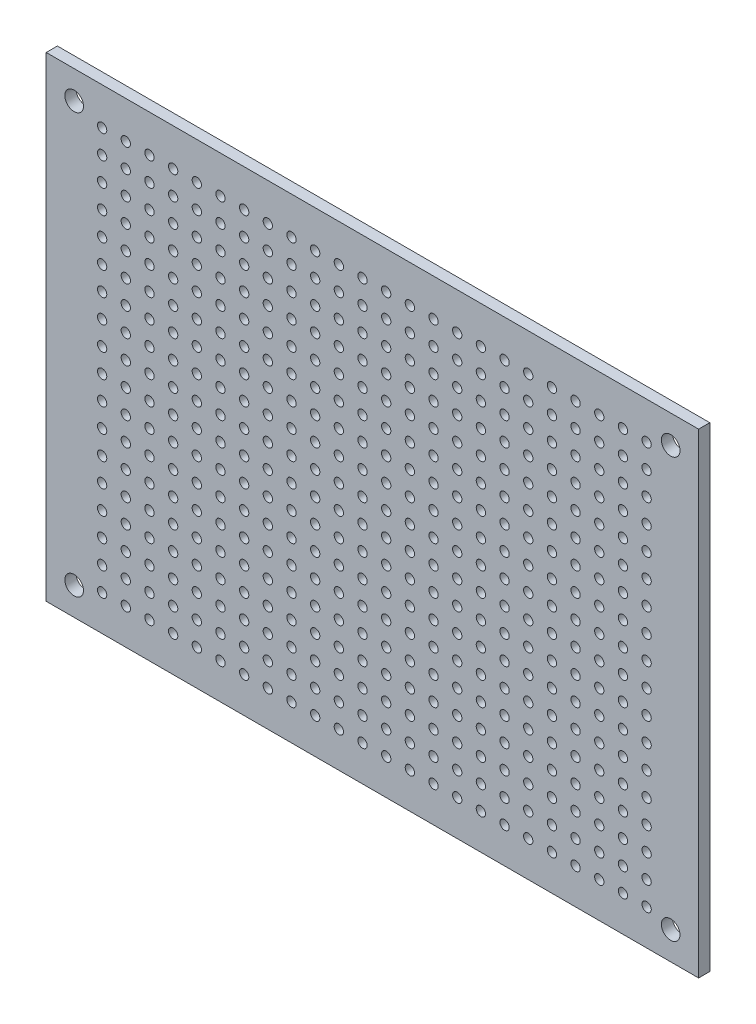
from build123d import *

# Parameters (mm, degrees)
SKETCH_1_W      = 70
SKETCH_1_H      = 51
SKETCH_1_R      = 0.5
SKETCH_1_R_2    = 1
EXTRUDE_1_DEPTH = 1.2


with BuildPart() as part:
    # Эскиз1 → Бобышка-Вытянуть1 (new body)
    with BuildSketch(Plane.XY):
        with Locations((35, 25.5)):
            Rectangle(SKETCH_1_W, SKETCH_1_H)
        with Locations((6, 47)):
            Circle(SKETCH_1_R, mode=Mode.SUBTRACT)
        with Locations((3, 48)):
            Circle(SKETCH_1_R_2, mode=Mode.SUBTRACT)
        with Locations((67, 48)):
            Circle(SKETCH_1_R_2, mode=Mode.SUBTRACT)
        with Locations((67, 3)):
            Circle(SKETCH_1_R_2, mode=Mode.SUBTRACT)
        with Locations((3, 3)):
            Circle(SKETCH_1_R_2, mode=Mode.SUBTRACT)
        with Locations((8.54, 47)):
            Circle(SKETCH_1_R, mode=Mode.SUBTRACT)
        with Locations((11.08, 47)):
            Circle(SKETCH_1_R, mode=Mode.SUBTRACT)
        with Locations((13.62, 47)):
            Circle(SKETCH_1_R, mode=Mode.SUBTRACT)
        with Locations((16.16, 47)):
            Circle(SKETCH_1_R, mode=Mode.SUBTRACT)
        with Locations((18.7, 47)):
            Circle(SKETCH_1_R, mode=Mode.SUBTRACT)
        with Locations((21.24, 47)):
            Circle(SKETCH_1_R, mode=Mode.SUBTRACT)
        with Locations((23.78, 47)):
            Circle(SKETCH_1_R, mode=Mode.SUBTRACT)
        with Locations((26.32, 47)):
            Circle(SKETCH_1_R, mode=Mode.SUBTRACT)
        with Locations((28.86, 47)):
            Circle(SKETCH_1_R, mode=Mode.SUBTRACT)
        with Locations((31.4, 47)):
            Circle(SKETCH_1_R, mode=Mode.SUBTRACT)
        with Locations((33.94, 47)):
            Circle(SKETCH_1_R, mode=Mode.SUBTRACT)
        with Locations((36.48, 47)):
            Circle(SKETCH_1_R, mode=Mode.SUBTRACT)
        with Locations((39.02, 47)):
            Circle(SKETCH_1_R, mode=Mode.SUBTRACT)
        with Locations((41.56, 47)):
            Circle(SKETCH_1_R, mode=Mode.SUBTRACT)
        with Locations((44.1, 47)):
            Circle(SKETCH_1_R, mode=Mode.SUBTRACT)
        with Locations((46.64, 47)):
            Circle(SKETCH_1_R, mode=Mode.SUBTRACT)
        with Locations((49.18, 47)):
            Circle(SKETCH_1_R, mode=Mode.SUBTRACT)
        with Locations((51.72, 47)):
            Circle(SKETCH_1_R, mode=Mode.SUBTRACT)
        with Locations((54.26, 47)):
            Circle(SKETCH_1_R, mode=Mode.SUBTRACT)
        with Locations((56.8, 47)):
            Circle(SKETCH_1_R, mode=Mode.SUBTRACT)
        with Locations((59.34, 47)):
            Circle(SKETCH_1_R, mode=Mode.SUBTRACT)
        with Locations((61.88, 47)):
            Circle(SKETCH_1_R, mode=Mode.SUBTRACT)
        with Locations((64.42, 47)):
            Circle(SKETCH_1_R, mode=Mode.SUBTRACT)
        with Locations((8.54, 44.46)):
            Circle(SKETCH_1_R, mode=Mode.SUBTRACT)
        with Locations((11.08, 44.46)):
            Circle(SKETCH_1_R, mode=Mode.SUBTRACT)
        with Locations((13.62, 44.46)):
            Circle(SKETCH_1_R, mode=Mode.SUBTRACT)
        with Locations((16.16, 44.46)):
            Circle(SKETCH_1_R, mode=Mode.SUBTRACT)
        with Locations((18.7, 44.46)):
            Circle(SKETCH_1_R, mode=Mode.SUBTRACT)
        with Locations((21.24, 44.46)):
            Circle(SKETCH_1_R, mode=Mode.SUBTRACT)
        with Locations((23.78, 44.46)):
            Circle(SKETCH_1_R, mode=Mode.SUBTRACT)
        with Locations((26.32, 44.46)):
            Circle(SKETCH_1_R, mode=Mode.SUBTRACT)
        with Locations((28.86, 44.46)):
            Circle(SKETCH_1_R, mode=Mode.SUBTRACT)
        with Locations((31.4, 44.46)):
            Circle(SKETCH_1_R, mode=Mode.SUBTRACT)
        with Locations((33.94, 44.46)):
            Circle(SKETCH_1_R, mode=Mode.SUBTRACT)
        with Locations((36.48, 44.46)):
            Circle(SKETCH_1_R, mode=Mode.SUBTRACT)
        with Locations((39.02, 44.46)):
            Circle(SKETCH_1_R, mode=Mode.SUBTRACT)
        with Locations((41.56, 44.46)):
            Circle(SKETCH_1_R, mode=Mode.SUBTRACT)
        with Locations((44.1, 44.46)):
            Circle(SKETCH_1_R, mode=Mode.SUBTRACT)
        with Locations((46.64, 44.46)):
            Circle(SKETCH_1_R, mode=Mode.SUBTRACT)
        with Locations((49.18, 44.46)):
            Circle(SKETCH_1_R, mode=Mode.SUBTRACT)
        with Locations((51.72, 44.46)):
            Circle(SKETCH_1_R, mode=Mode.SUBTRACT)
        with Locations((54.26, 44.46)):
            Circle(SKETCH_1_R, mode=Mode.SUBTRACT)
        with Locations((56.8, 44.46)):
            Circle(SKETCH_1_R, mode=Mode.SUBTRACT)
        with Locations((59.34, 44.46)):
            Circle(SKETCH_1_R, mode=Mode.SUBTRACT)
        with Locations((61.88, 44.46)):
            Circle(SKETCH_1_R, mode=Mode.SUBTRACT)
        with Locations((64.42, 44.46)):
            Circle(SKETCH_1_R, mode=Mode.SUBTRACT)
        with Locations((8.54, 41.92)):
            Circle(SKETCH_1_R, mode=Mode.SUBTRACT)
        with Locations((11.08, 41.92)):
            Circle(SKETCH_1_R, mode=Mode.SUBTRACT)
        with Locations((13.62, 41.92)):
            Circle(SKETCH_1_R, mode=Mode.SUBTRACT)
        with Locations((16.16, 41.92)):
            Circle(SKETCH_1_R, mode=Mode.SUBTRACT)
        with Locations((18.7, 41.92)):
            Circle(SKETCH_1_R, mode=Mode.SUBTRACT)
        with Locations((21.24, 41.92)):
            Circle(SKETCH_1_R, mode=Mode.SUBTRACT)
        with Locations((23.78, 41.92)):
            Circle(SKETCH_1_R, mode=Mode.SUBTRACT)
        with Locations((26.32, 41.92)):
            Circle(SKETCH_1_R, mode=Mode.SUBTRACT)
        with Locations((28.86, 41.92)):
            Circle(SKETCH_1_R, mode=Mode.SUBTRACT)
        with Locations((31.4, 41.92)):
            Circle(SKETCH_1_R, mode=Mode.SUBTRACT)
        with Locations((33.94, 41.92)):
            Circle(SKETCH_1_R, mode=Mode.SUBTRACT)
        with Locations((36.48, 41.92)):
            Circle(SKETCH_1_R, mode=Mode.SUBTRACT)
        with Locations((39.02, 41.92)):
            Circle(SKETCH_1_R, mode=Mode.SUBTRACT)
        with Locations((41.56, 41.92)):
            Circle(SKETCH_1_R, mode=Mode.SUBTRACT)
        with Locations((44.1, 41.92)):
            Circle(SKETCH_1_R, mode=Mode.SUBTRACT)
        with Locations((46.64, 41.92)):
            Circle(SKETCH_1_R, mode=Mode.SUBTRACT)
        with Locations((49.18, 41.92)):
            Circle(SKETCH_1_R, mode=Mode.SUBTRACT)
        with Locations((51.72, 41.92)):
            Circle(SKETCH_1_R, mode=Mode.SUBTRACT)
        with Locations((54.26, 41.92)):
            Circle(SKETCH_1_R, mode=Mode.SUBTRACT)
        with Locations((56.8, 41.92)):
            Circle(SKETCH_1_R, mode=Mode.SUBTRACT)
        with Locations((59.34, 41.92)):
            Circle(SKETCH_1_R, mode=Mode.SUBTRACT)
        with Locations((61.88, 41.92)):
            Circle(SKETCH_1_R, mode=Mode.SUBTRACT)
        with Locations((64.42, 41.92)):
            Circle(SKETCH_1_R, mode=Mode.SUBTRACT)
        with Locations((8.54, 39.38)):
            Circle(SKETCH_1_R, mode=Mode.SUBTRACT)
        with Locations((11.08, 39.38)):
            Circle(SKETCH_1_R, mode=Mode.SUBTRACT)
        with Locations((13.62, 39.38)):
            Circle(SKETCH_1_R, mode=Mode.SUBTRACT)
        with Locations((16.16, 39.38)):
            Circle(SKETCH_1_R, mode=Mode.SUBTRACT)
        with Locations((18.7, 39.38)):
            Circle(SKETCH_1_R, mode=Mode.SUBTRACT)
        with Locations((21.24, 39.38)):
            Circle(SKETCH_1_R, mode=Mode.SUBTRACT)
        with Locations((23.78, 39.38)):
            Circle(SKETCH_1_R, mode=Mode.SUBTRACT)
        with Locations((26.32, 39.38)):
            Circle(SKETCH_1_R, mode=Mode.SUBTRACT)
        with Locations((28.86, 39.38)):
            Circle(SKETCH_1_R, mode=Mode.SUBTRACT)
        with Locations((31.4, 39.38)):
            Circle(SKETCH_1_R, mode=Mode.SUBTRACT)
        with Locations((33.94, 39.38)):
            Circle(SKETCH_1_R, mode=Mode.SUBTRACT)
        with Locations((36.48, 39.38)):
            Circle(SKETCH_1_R, mode=Mode.SUBTRACT)
        with Locations((39.02, 39.38)):
            Circle(SKETCH_1_R, mode=Mode.SUBTRACT)
        with Locations((41.56, 39.38)):
            Circle(SKETCH_1_R, mode=Mode.SUBTRACT)
        with Locations((44.1, 39.38)):
            Circle(SKETCH_1_R, mode=Mode.SUBTRACT)
        with Locations((46.64, 39.38)):
            Circle(SKETCH_1_R, mode=Mode.SUBTRACT)
        with Locations((49.18, 39.38)):
            Circle(SKETCH_1_R, mode=Mode.SUBTRACT)
        with Locations((51.72, 39.38)):
            Circle(SKETCH_1_R, mode=Mode.SUBTRACT)
        with Locations((54.26, 39.38)):
            Circle(SKETCH_1_R, mode=Mode.SUBTRACT)
        with Locations((56.8, 39.38)):
            Circle(SKETCH_1_R, mode=Mode.SUBTRACT)
        with Locations((59.34, 39.38)):
            Circle(SKETCH_1_R, mode=Mode.SUBTRACT)
        with Locations((61.88, 39.38)):
            Circle(SKETCH_1_R, mode=Mode.SUBTRACT)
        with Locations((64.42, 39.38)):
            Circle(SKETCH_1_R, mode=Mode.SUBTRACT)
        with Locations((8.54, 36.84)):
            Circle(SKETCH_1_R, mode=Mode.SUBTRACT)
        with Locations((11.08, 36.84)):
            Circle(SKETCH_1_R, mode=Mode.SUBTRACT)
        with Locations((13.62, 36.84)):
            Circle(SKETCH_1_R, mode=Mode.SUBTRACT)
        with Locations((16.16, 36.84)):
            Circle(SKETCH_1_R, mode=Mode.SUBTRACT)
        with Locations((18.7, 36.84)):
            Circle(SKETCH_1_R, mode=Mode.SUBTRACT)
        with Locations((21.24, 36.84)):
            Circle(SKETCH_1_R, mode=Mode.SUBTRACT)
        with Locations((23.78, 36.84)):
            Circle(SKETCH_1_R, mode=Mode.SUBTRACT)
        with Locations((26.32, 36.84)):
            Circle(SKETCH_1_R, mode=Mode.SUBTRACT)
        with Locations((28.86, 36.84)):
            Circle(SKETCH_1_R, mode=Mode.SUBTRACT)
        with Locations((31.4, 36.84)):
            Circle(SKETCH_1_R, mode=Mode.SUBTRACT)
        with Locations((33.94, 36.84)):
            Circle(SKETCH_1_R, mode=Mode.SUBTRACT)
        with Locations((36.48, 36.84)):
            Circle(SKETCH_1_R, mode=Mode.SUBTRACT)
        with Locations((39.02, 36.84)):
            Circle(SKETCH_1_R, mode=Mode.SUBTRACT)
        with Locations((41.56, 36.84)):
            Circle(SKETCH_1_R, mode=Mode.SUBTRACT)
        with Locations((44.1, 36.84)):
            Circle(SKETCH_1_R, mode=Mode.SUBTRACT)
        with Locations((46.64, 36.84)):
            Circle(SKETCH_1_R, mode=Mode.SUBTRACT)
        with Locations((49.18, 36.84)):
            Circle(SKETCH_1_R, mode=Mode.SUBTRACT)
        with Locations((51.72, 36.84)):
            Circle(SKETCH_1_R, mode=Mode.SUBTRACT)
        with Locations((54.26, 36.84)):
            Circle(SKETCH_1_R, mode=Mode.SUBTRACT)
        with Locations((56.8, 36.84)):
            Circle(SKETCH_1_R, mode=Mode.SUBTRACT)
        with Locations((59.34, 36.84)):
            Circle(SKETCH_1_R, mode=Mode.SUBTRACT)
        with Locations((61.88, 36.84)):
            Circle(SKETCH_1_R, mode=Mode.SUBTRACT)
        with Locations((64.42, 36.84)):
            Circle(SKETCH_1_R, mode=Mode.SUBTRACT)
        with Locations((8.54, 34.3)):
            Circle(SKETCH_1_R, mode=Mode.SUBTRACT)
        with Locations((11.08, 34.3)):
            Circle(SKETCH_1_R, mode=Mode.SUBTRACT)
        with Locations((13.62, 34.3)):
            Circle(SKETCH_1_R, mode=Mode.SUBTRACT)
        with Locations((16.16, 34.3)):
            Circle(SKETCH_1_R, mode=Mode.SUBTRACT)
        with Locations((18.7, 34.3)):
            Circle(SKETCH_1_R, mode=Mode.SUBTRACT)
        with Locations((21.24, 34.3)):
            Circle(SKETCH_1_R, mode=Mode.SUBTRACT)
        with Locations((23.78, 34.3)):
            Circle(SKETCH_1_R, mode=Mode.SUBTRACT)
        with Locations((26.32, 34.3)):
            Circle(SKETCH_1_R, mode=Mode.SUBTRACT)
        with Locations((28.86, 34.3)):
            Circle(SKETCH_1_R, mode=Mode.SUBTRACT)
        with Locations((31.4, 34.3)):
            Circle(SKETCH_1_R, mode=Mode.SUBTRACT)
        with Locations((33.94, 34.3)):
            Circle(SKETCH_1_R, mode=Mode.SUBTRACT)
        with Locations((36.48, 34.3)):
            Circle(SKETCH_1_R, mode=Mode.SUBTRACT)
        with Locations((39.02, 34.3)):
            Circle(SKETCH_1_R, mode=Mode.SUBTRACT)
        with Locations((41.56, 34.3)):
            Circle(SKETCH_1_R, mode=Mode.SUBTRACT)
        with Locations((44.1, 34.3)):
            Circle(SKETCH_1_R, mode=Mode.SUBTRACT)
        with Locations((46.64, 34.3)):
            Circle(SKETCH_1_R, mode=Mode.SUBTRACT)
        with Locations((49.18, 34.3)):
            Circle(SKETCH_1_R, mode=Mode.SUBTRACT)
        with Locations((51.72, 34.3)):
            Circle(SKETCH_1_R, mode=Mode.SUBTRACT)
        with Locations((54.26, 34.3)):
            Circle(SKETCH_1_R, mode=Mode.SUBTRACT)
        with Locations((56.8, 34.3)):
            Circle(SKETCH_1_R, mode=Mode.SUBTRACT)
        with Locations((59.34, 34.3)):
            Circle(SKETCH_1_R, mode=Mode.SUBTRACT)
        with Locations((61.88, 34.3)):
            Circle(SKETCH_1_R, mode=Mode.SUBTRACT)
        with Locations((64.42, 34.3)):
            Circle(SKETCH_1_R, mode=Mode.SUBTRACT)
        with Locations((8.54, 31.76)):
            Circle(SKETCH_1_R, mode=Mode.SUBTRACT)
        with Locations((11.08, 31.76)):
            Circle(SKETCH_1_R, mode=Mode.SUBTRACT)
        with Locations((13.62, 31.76)):
            Circle(SKETCH_1_R, mode=Mode.SUBTRACT)
        with Locations((16.16, 31.76)):
            Circle(SKETCH_1_R, mode=Mode.SUBTRACT)
        with Locations((18.7, 31.76)):
            Circle(SKETCH_1_R, mode=Mode.SUBTRACT)
        with Locations((21.24, 31.76)):
            Circle(SKETCH_1_R, mode=Mode.SUBTRACT)
        with Locations((23.78, 31.76)):
            Circle(SKETCH_1_R, mode=Mode.SUBTRACT)
        with Locations((26.32, 31.76)):
            Circle(SKETCH_1_R, mode=Mode.SUBTRACT)
        with Locations((28.86, 31.76)):
            Circle(SKETCH_1_R, mode=Mode.SUBTRACT)
        with Locations((31.4, 31.76)):
            Circle(SKETCH_1_R, mode=Mode.SUBTRACT)
        with Locations((33.94, 31.76)):
            Circle(SKETCH_1_R, mode=Mode.SUBTRACT)
        with Locations((36.48, 31.76)):
            Circle(SKETCH_1_R, mode=Mode.SUBTRACT)
        with Locations((39.02, 31.76)):
            Circle(SKETCH_1_R, mode=Mode.SUBTRACT)
        with Locations((41.56, 31.76)):
            Circle(SKETCH_1_R, mode=Mode.SUBTRACT)
        with Locations((44.1, 31.76)):
            Circle(SKETCH_1_R, mode=Mode.SUBTRACT)
        with Locations((46.64, 31.76)):
            Circle(SKETCH_1_R, mode=Mode.SUBTRACT)
        with Locations((49.18, 31.76)):
            Circle(SKETCH_1_R, mode=Mode.SUBTRACT)
        with Locations((51.72, 31.76)):
            Circle(SKETCH_1_R, mode=Mode.SUBTRACT)
        with Locations((54.26, 31.76)):
            Circle(SKETCH_1_R, mode=Mode.SUBTRACT)
        with Locations((56.8, 31.76)):
            Circle(SKETCH_1_R, mode=Mode.SUBTRACT)
        with Locations((59.34, 31.76)):
            Circle(SKETCH_1_R, mode=Mode.SUBTRACT)
        with Locations((61.88, 31.76)):
            Circle(SKETCH_1_R, mode=Mode.SUBTRACT)
        with Locations((64.42, 31.76)):
            Circle(SKETCH_1_R, mode=Mode.SUBTRACT)
        with Locations((8.54, 29.22)):
            Circle(SKETCH_1_R, mode=Mode.SUBTRACT)
        with Locations((11.08, 29.22)):
            Circle(SKETCH_1_R, mode=Mode.SUBTRACT)
        with Locations((13.62, 29.22)):
            Circle(SKETCH_1_R, mode=Mode.SUBTRACT)
        with Locations((16.16, 29.22)):
            Circle(SKETCH_1_R, mode=Mode.SUBTRACT)
        with Locations((18.7, 29.22)):
            Circle(SKETCH_1_R, mode=Mode.SUBTRACT)
        with Locations((21.24, 29.22)):
            Circle(SKETCH_1_R, mode=Mode.SUBTRACT)
        with Locations((23.78, 29.22)):
            Circle(SKETCH_1_R, mode=Mode.SUBTRACT)
        with Locations((26.32, 29.22)):
            Circle(SKETCH_1_R, mode=Mode.SUBTRACT)
        with Locations((28.86, 29.22)):
            Circle(SKETCH_1_R, mode=Mode.SUBTRACT)
        with Locations((31.4, 29.22)):
            Circle(SKETCH_1_R, mode=Mode.SUBTRACT)
        with Locations((33.94, 29.22)):
            Circle(SKETCH_1_R, mode=Mode.SUBTRACT)
        with Locations((36.48, 29.22)):
            Circle(SKETCH_1_R, mode=Mode.SUBTRACT)
        with Locations((39.02, 29.22)):
            Circle(SKETCH_1_R, mode=Mode.SUBTRACT)
        with Locations((41.56, 29.22)):
            Circle(SKETCH_1_R, mode=Mode.SUBTRACT)
        with Locations((44.1, 29.22)):
            Circle(SKETCH_1_R, mode=Mode.SUBTRACT)
        with Locations((46.64, 29.22)):
            Circle(SKETCH_1_R, mode=Mode.SUBTRACT)
        with Locations((49.18, 29.22)):
            Circle(SKETCH_1_R, mode=Mode.SUBTRACT)
        with Locations((51.72, 29.22)):
            Circle(SKETCH_1_R, mode=Mode.SUBTRACT)
        with Locations((54.26, 29.22)):
            Circle(SKETCH_1_R, mode=Mode.SUBTRACT)
        with Locations((56.8, 29.22)):
            Circle(SKETCH_1_R, mode=Mode.SUBTRACT)
        with Locations((59.34, 29.22)):
            Circle(SKETCH_1_R, mode=Mode.SUBTRACT)
        with Locations((61.88, 29.22)):
            Circle(SKETCH_1_R, mode=Mode.SUBTRACT)
        with Locations((64.42, 29.22)):
            Circle(SKETCH_1_R, mode=Mode.SUBTRACT)
        with Locations((8.54, 26.68)):
            Circle(SKETCH_1_R, mode=Mode.SUBTRACT)
        with Locations((11.08, 26.68)):
            Circle(SKETCH_1_R, mode=Mode.SUBTRACT)
        with Locations((13.62, 26.68)):
            Circle(SKETCH_1_R, mode=Mode.SUBTRACT)
        with Locations((16.16, 26.68)):
            Circle(SKETCH_1_R, mode=Mode.SUBTRACT)
        with Locations((18.7, 26.68)):
            Circle(SKETCH_1_R, mode=Mode.SUBTRACT)
        with Locations((21.24, 26.68)):
            Circle(SKETCH_1_R, mode=Mode.SUBTRACT)
        with Locations((23.78, 26.68)):
            Circle(SKETCH_1_R, mode=Mode.SUBTRACT)
        with Locations((26.32, 26.68)):
            Circle(SKETCH_1_R, mode=Mode.SUBTRACT)
        with Locations((28.86, 26.68)):
            Circle(SKETCH_1_R, mode=Mode.SUBTRACT)
        with Locations((31.4, 26.68)):
            Circle(SKETCH_1_R, mode=Mode.SUBTRACT)
        with Locations((33.94, 26.68)):
            Circle(SKETCH_1_R, mode=Mode.SUBTRACT)
        with Locations((36.48, 26.68)):
            Circle(SKETCH_1_R, mode=Mode.SUBTRACT)
        with Locations((39.02, 26.68)):
            Circle(SKETCH_1_R, mode=Mode.SUBTRACT)
        with Locations((41.56, 26.68)):
            Circle(SKETCH_1_R, mode=Mode.SUBTRACT)
        with Locations((44.1, 26.68)):
            Circle(SKETCH_1_R, mode=Mode.SUBTRACT)
        with Locations((46.64, 26.68)):
            Circle(SKETCH_1_R, mode=Mode.SUBTRACT)
        with Locations((49.18, 26.68)):
            Circle(SKETCH_1_R, mode=Mode.SUBTRACT)
        with Locations((51.72, 26.68)):
            Circle(SKETCH_1_R, mode=Mode.SUBTRACT)
        with Locations((54.26, 26.68)):
            Circle(SKETCH_1_R, mode=Mode.SUBTRACT)
        with Locations((56.8, 26.68)):
            Circle(SKETCH_1_R, mode=Mode.SUBTRACT)
        with Locations((59.34, 26.68)):
            Circle(SKETCH_1_R, mode=Mode.SUBTRACT)
        with Locations((61.88, 26.68)):
            Circle(SKETCH_1_R, mode=Mode.SUBTRACT)
        with Locations((64.42, 26.68)):
            Circle(SKETCH_1_R, mode=Mode.SUBTRACT)
        with Locations((8.54, 24.14)):
            Circle(SKETCH_1_R, mode=Mode.SUBTRACT)
        with Locations((11.08, 24.14)):
            Circle(SKETCH_1_R, mode=Mode.SUBTRACT)
        with Locations((13.62, 24.14)):
            Circle(SKETCH_1_R, mode=Mode.SUBTRACT)
        with Locations((16.16, 24.14)):
            Circle(SKETCH_1_R, mode=Mode.SUBTRACT)
        with Locations((18.7, 24.14)):
            Circle(SKETCH_1_R, mode=Mode.SUBTRACT)
        with Locations((21.24, 24.14)):
            Circle(SKETCH_1_R, mode=Mode.SUBTRACT)
        with Locations((23.78, 24.14)):
            Circle(SKETCH_1_R, mode=Mode.SUBTRACT)
        with Locations((26.32, 24.14)):
            Circle(SKETCH_1_R, mode=Mode.SUBTRACT)
        with Locations((28.86, 24.14)):
            Circle(SKETCH_1_R, mode=Mode.SUBTRACT)
        with Locations((31.4, 24.14)):
            Circle(SKETCH_1_R, mode=Mode.SUBTRACT)
        with Locations((33.94, 24.14)):
            Circle(SKETCH_1_R, mode=Mode.SUBTRACT)
        with Locations((36.48, 24.14)):
            Circle(SKETCH_1_R, mode=Mode.SUBTRACT)
        with Locations((39.02, 24.14)):
            Circle(SKETCH_1_R, mode=Mode.SUBTRACT)
        with Locations((41.56, 24.14)):
            Circle(SKETCH_1_R, mode=Mode.SUBTRACT)
        with Locations((44.1, 24.14)):
            Circle(SKETCH_1_R, mode=Mode.SUBTRACT)
        with Locations((46.64, 24.14)):
            Circle(SKETCH_1_R, mode=Mode.SUBTRACT)
        with Locations((49.18, 24.14)):
            Circle(SKETCH_1_R, mode=Mode.SUBTRACT)
        with Locations((51.72, 24.14)):
            Circle(SKETCH_1_R, mode=Mode.SUBTRACT)
        with Locations((54.26, 24.14)):
            Circle(SKETCH_1_R, mode=Mode.SUBTRACT)
        with Locations((56.8, 24.14)):
            Circle(SKETCH_1_R, mode=Mode.SUBTRACT)
        with Locations((59.34, 24.14)):
            Circle(SKETCH_1_R, mode=Mode.SUBTRACT)
        with Locations((61.88, 24.14)):
            Circle(SKETCH_1_R, mode=Mode.SUBTRACT)
        with Locations((64.42, 24.14)):
            Circle(SKETCH_1_R, mode=Mode.SUBTRACT)
        with Locations((8.54, 21.6)):
            Circle(SKETCH_1_R, mode=Mode.SUBTRACT)
        with Locations((11.08, 21.6)):
            Circle(SKETCH_1_R, mode=Mode.SUBTRACT)
        with Locations((13.62, 21.6)):
            Circle(SKETCH_1_R, mode=Mode.SUBTRACT)
        with Locations((16.16, 21.6)):
            Circle(SKETCH_1_R, mode=Mode.SUBTRACT)
        with Locations((18.7, 21.6)):
            Circle(SKETCH_1_R, mode=Mode.SUBTRACT)
        with Locations((21.24, 21.6)):
            Circle(SKETCH_1_R, mode=Mode.SUBTRACT)
        with Locations((23.78, 21.6)):
            Circle(SKETCH_1_R, mode=Mode.SUBTRACT)
        with Locations((26.32, 21.6)):
            Circle(SKETCH_1_R, mode=Mode.SUBTRACT)
        with Locations((28.86, 21.6)):
            Circle(SKETCH_1_R, mode=Mode.SUBTRACT)
        with Locations((31.4, 21.6)):
            Circle(SKETCH_1_R, mode=Mode.SUBTRACT)
        with Locations((33.94, 21.6)):
            Circle(SKETCH_1_R, mode=Mode.SUBTRACT)
        with Locations((36.48, 21.6)):
            Circle(SKETCH_1_R, mode=Mode.SUBTRACT)
        with Locations((39.02, 21.6)):
            Circle(SKETCH_1_R, mode=Mode.SUBTRACT)
        with Locations((41.56, 21.6)):
            Circle(SKETCH_1_R, mode=Mode.SUBTRACT)
        with Locations((44.1, 21.6)):
            Circle(SKETCH_1_R, mode=Mode.SUBTRACT)
        with Locations((46.64, 21.6)):
            Circle(SKETCH_1_R, mode=Mode.SUBTRACT)
        with Locations((49.18, 21.6)):
            Circle(SKETCH_1_R, mode=Mode.SUBTRACT)
        with Locations((51.72, 21.6)):
            Circle(SKETCH_1_R, mode=Mode.SUBTRACT)
        with Locations((54.26, 21.6)):
            Circle(SKETCH_1_R, mode=Mode.SUBTRACT)
        with Locations((56.8, 21.6)):
            Circle(SKETCH_1_R, mode=Mode.SUBTRACT)
        with Locations((59.34, 21.6)):
            Circle(SKETCH_1_R, mode=Mode.SUBTRACT)
        with Locations((61.88, 21.6)):
            Circle(SKETCH_1_R, mode=Mode.SUBTRACT)
        with Locations((64.42, 21.6)):
            Circle(SKETCH_1_R, mode=Mode.SUBTRACT)
        with Locations((8.54, 19.06)):
            Circle(SKETCH_1_R, mode=Mode.SUBTRACT)
        with Locations((11.08, 19.06)):
            Circle(SKETCH_1_R, mode=Mode.SUBTRACT)
        with Locations((13.62, 19.06)):
            Circle(SKETCH_1_R, mode=Mode.SUBTRACT)
        with Locations((16.16, 19.06)):
            Circle(SKETCH_1_R, mode=Mode.SUBTRACT)
        with Locations((18.7, 19.06)):
            Circle(SKETCH_1_R, mode=Mode.SUBTRACT)
        with Locations((21.24, 19.06)):
            Circle(SKETCH_1_R, mode=Mode.SUBTRACT)
        with Locations((23.78, 19.06)):
            Circle(SKETCH_1_R, mode=Mode.SUBTRACT)
        with Locations((26.32, 19.06)):
            Circle(SKETCH_1_R, mode=Mode.SUBTRACT)
        with Locations((28.86, 19.06)):
            Circle(SKETCH_1_R, mode=Mode.SUBTRACT)
        with Locations((31.4, 19.06)):
            Circle(SKETCH_1_R, mode=Mode.SUBTRACT)
        with Locations((33.94, 19.06)):
            Circle(SKETCH_1_R, mode=Mode.SUBTRACT)
        with Locations((36.48, 19.06)):
            Circle(SKETCH_1_R, mode=Mode.SUBTRACT)
        with Locations((39.02, 19.06)):
            Circle(SKETCH_1_R, mode=Mode.SUBTRACT)
        with Locations((41.56, 19.06)):
            Circle(SKETCH_1_R, mode=Mode.SUBTRACT)
        with Locations((44.1, 19.06)):
            Circle(SKETCH_1_R, mode=Mode.SUBTRACT)
        with Locations((46.64, 19.06)):
            Circle(SKETCH_1_R, mode=Mode.SUBTRACT)
        with Locations((49.18, 19.06)):
            Circle(SKETCH_1_R, mode=Mode.SUBTRACT)
        with Locations((51.72, 19.06)):
            Circle(SKETCH_1_R, mode=Mode.SUBTRACT)
        with Locations((54.26, 19.06)):
            Circle(SKETCH_1_R, mode=Mode.SUBTRACT)
        with Locations((56.8, 19.06)):
            Circle(SKETCH_1_R, mode=Mode.SUBTRACT)
        with Locations((59.34, 19.06)):
            Circle(SKETCH_1_R, mode=Mode.SUBTRACT)
        with Locations((61.88, 19.06)):
            Circle(SKETCH_1_R, mode=Mode.SUBTRACT)
        with Locations((64.42, 19.06)):
            Circle(SKETCH_1_R, mode=Mode.SUBTRACT)
        with Locations((8.54, 16.52)):
            Circle(SKETCH_1_R, mode=Mode.SUBTRACT)
        with Locations((11.08, 16.52)):
            Circle(SKETCH_1_R, mode=Mode.SUBTRACT)
        with Locations((13.62, 16.52)):
            Circle(SKETCH_1_R, mode=Mode.SUBTRACT)
        with Locations((16.16, 16.52)):
            Circle(SKETCH_1_R, mode=Mode.SUBTRACT)
        with Locations((18.7, 16.52)):
            Circle(SKETCH_1_R, mode=Mode.SUBTRACT)
        with Locations((21.24, 16.52)):
            Circle(SKETCH_1_R, mode=Mode.SUBTRACT)
        with Locations((23.78, 16.52)):
            Circle(SKETCH_1_R, mode=Mode.SUBTRACT)
        with Locations((26.32, 16.52)):
            Circle(SKETCH_1_R, mode=Mode.SUBTRACT)
        with Locations((28.86, 16.52)):
            Circle(SKETCH_1_R, mode=Mode.SUBTRACT)
        with Locations((31.4, 16.52)):
            Circle(SKETCH_1_R, mode=Mode.SUBTRACT)
        with Locations((33.94, 16.52)):
            Circle(SKETCH_1_R, mode=Mode.SUBTRACT)
        with Locations((36.48, 16.52)):
            Circle(SKETCH_1_R, mode=Mode.SUBTRACT)
        with Locations((39.02, 16.52)):
            Circle(SKETCH_1_R, mode=Mode.SUBTRACT)
        with Locations((41.56, 16.52)):
            Circle(SKETCH_1_R, mode=Mode.SUBTRACT)
        with Locations((44.1, 16.52)):
            Circle(SKETCH_1_R, mode=Mode.SUBTRACT)
        with Locations((46.64, 16.52)):
            Circle(SKETCH_1_R, mode=Mode.SUBTRACT)
        with Locations((49.18, 16.52)):
            Circle(SKETCH_1_R, mode=Mode.SUBTRACT)
        with Locations((51.72, 16.52)):
            Circle(SKETCH_1_R, mode=Mode.SUBTRACT)
        with Locations((54.26, 16.52)):
            Circle(SKETCH_1_R, mode=Mode.SUBTRACT)
        with Locations((56.8, 16.52)):
            Circle(SKETCH_1_R, mode=Mode.SUBTRACT)
        with Locations((59.34, 16.52)):
            Circle(SKETCH_1_R, mode=Mode.SUBTRACT)
        with Locations((61.88, 16.52)):
            Circle(SKETCH_1_R, mode=Mode.SUBTRACT)
        with Locations((64.42, 16.52)):
            Circle(SKETCH_1_R, mode=Mode.SUBTRACT)
        with Locations((8.54, 13.98)):
            Circle(SKETCH_1_R, mode=Mode.SUBTRACT)
        with Locations((11.08, 13.98)):
            Circle(SKETCH_1_R, mode=Mode.SUBTRACT)
        with Locations((13.62, 13.98)):
            Circle(SKETCH_1_R, mode=Mode.SUBTRACT)
        with Locations((16.16, 13.98)):
            Circle(SKETCH_1_R, mode=Mode.SUBTRACT)
        with Locations((18.7, 13.98)):
            Circle(SKETCH_1_R, mode=Mode.SUBTRACT)
        with Locations((21.24, 13.98)):
            Circle(SKETCH_1_R, mode=Mode.SUBTRACT)
        with Locations((23.78, 13.98)):
            Circle(SKETCH_1_R, mode=Mode.SUBTRACT)
        with Locations((26.32, 13.98)):
            Circle(SKETCH_1_R, mode=Mode.SUBTRACT)
        with Locations((28.86, 13.98)):
            Circle(SKETCH_1_R, mode=Mode.SUBTRACT)
        with Locations((31.4, 13.98)):
            Circle(SKETCH_1_R, mode=Mode.SUBTRACT)
        with Locations((33.94, 13.98)):
            Circle(SKETCH_1_R, mode=Mode.SUBTRACT)
        with Locations((36.48, 13.98)):
            Circle(SKETCH_1_R, mode=Mode.SUBTRACT)
        with Locations((39.02, 13.98)):
            Circle(SKETCH_1_R, mode=Mode.SUBTRACT)
        with Locations((41.56, 13.98)):
            Circle(SKETCH_1_R, mode=Mode.SUBTRACT)
        with Locations((44.1, 13.98)):
            Circle(SKETCH_1_R, mode=Mode.SUBTRACT)
        with Locations((46.64, 13.98)):
            Circle(SKETCH_1_R, mode=Mode.SUBTRACT)
        with Locations((49.18, 13.98)):
            Circle(SKETCH_1_R, mode=Mode.SUBTRACT)
        with Locations((51.72, 13.98)):
            Circle(SKETCH_1_R, mode=Mode.SUBTRACT)
        with Locations((54.26, 13.98)):
            Circle(SKETCH_1_R, mode=Mode.SUBTRACT)
        with Locations((56.8, 13.98)):
            Circle(SKETCH_1_R, mode=Mode.SUBTRACT)
        with Locations((59.34, 13.98)):
            Circle(SKETCH_1_R, mode=Mode.SUBTRACT)
        with Locations((61.88, 13.98)):
            Circle(SKETCH_1_R, mode=Mode.SUBTRACT)
        with Locations((64.42, 13.98)):
            Circle(SKETCH_1_R, mode=Mode.SUBTRACT)
        with Locations((8.54, 11.44)):
            Circle(SKETCH_1_R, mode=Mode.SUBTRACT)
        with Locations((11.08, 11.44)):
            Circle(SKETCH_1_R, mode=Mode.SUBTRACT)
        with Locations((13.62, 11.44)):
            Circle(SKETCH_1_R, mode=Mode.SUBTRACT)
        with Locations((16.16, 11.44)):
            Circle(SKETCH_1_R, mode=Mode.SUBTRACT)
        with Locations((18.7, 11.44)):
            Circle(SKETCH_1_R, mode=Mode.SUBTRACT)
        with Locations((21.24, 11.44)):
            Circle(SKETCH_1_R, mode=Mode.SUBTRACT)
        with Locations((23.78, 11.44)):
            Circle(SKETCH_1_R, mode=Mode.SUBTRACT)
        with Locations((26.32, 11.44)):
            Circle(SKETCH_1_R, mode=Mode.SUBTRACT)
        with Locations((28.86, 11.44)):
            Circle(SKETCH_1_R, mode=Mode.SUBTRACT)
        with Locations((31.4, 11.44)):
            Circle(SKETCH_1_R, mode=Mode.SUBTRACT)
        with Locations((33.94, 11.44)):
            Circle(SKETCH_1_R, mode=Mode.SUBTRACT)
        with Locations((36.48, 11.44)):
            Circle(SKETCH_1_R, mode=Mode.SUBTRACT)
        with Locations((39.02, 11.44)):
            Circle(SKETCH_1_R, mode=Mode.SUBTRACT)
        with Locations((41.56, 11.44)):
            Circle(SKETCH_1_R, mode=Mode.SUBTRACT)
        with Locations((44.1, 11.44)):
            Circle(SKETCH_1_R, mode=Mode.SUBTRACT)
        with Locations((46.64, 11.44)):
            Circle(SKETCH_1_R, mode=Mode.SUBTRACT)
        with Locations((49.18, 11.44)):
            Circle(SKETCH_1_R, mode=Mode.SUBTRACT)
        with Locations((51.72, 11.44)):
            Circle(SKETCH_1_R, mode=Mode.SUBTRACT)
        with Locations((54.26, 11.44)):
            Circle(SKETCH_1_R, mode=Mode.SUBTRACT)
        with Locations((56.8, 11.44)):
            Circle(SKETCH_1_R, mode=Mode.SUBTRACT)
        with Locations((59.34, 11.44)):
            Circle(SKETCH_1_R, mode=Mode.SUBTRACT)
        with Locations((61.88, 11.44)):
            Circle(SKETCH_1_R, mode=Mode.SUBTRACT)
        with Locations((64.42, 11.44)):
            Circle(SKETCH_1_R, mode=Mode.SUBTRACT)
        with Locations((8.54, 8.9)):
            Circle(SKETCH_1_R, mode=Mode.SUBTRACT)
        with Locations((11.08, 8.9)):
            Circle(SKETCH_1_R, mode=Mode.SUBTRACT)
        with Locations((13.62, 8.9)):
            Circle(SKETCH_1_R, mode=Mode.SUBTRACT)
        with Locations((16.16, 8.9)):
            Circle(SKETCH_1_R, mode=Mode.SUBTRACT)
        with Locations((18.7, 8.9)):
            Circle(SKETCH_1_R, mode=Mode.SUBTRACT)
        with Locations((21.24, 8.9)):
            Circle(SKETCH_1_R, mode=Mode.SUBTRACT)
        with Locations((23.78, 8.9)):
            Circle(SKETCH_1_R, mode=Mode.SUBTRACT)
        with Locations((26.32, 8.9)):
            Circle(SKETCH_1_R, mode=Mode.SUBTRACT)
        with Locations((28.86, 8.9)):
            Circle(SKETCH_1_R, mode=Mode.SUBTRACT)
        with Locations((31.4, 8.9)):
            Circle(SKETCH_1_R, mode=Mode.SUBTRACT)
        with Locations((33.94, 8.9)):
            Circle(SKETCH_1_R, mode=Mode.SUBTRACT)
        with Locations((36.48, 8.9)):
            Circle(SKETCH_1_R, mode=Mode.SUBTRACT)
        with Locations((39.02, 8.9)):
            Circle(SKETCH_1_R, mode=Mode.SUBTRACT)
        with Locations((41.56, 8.9)):
            Circle(SKETCH_1_R, mode=Mode.SUBTRACT)
        with Locations((44.1, 8.9)):
            Circle(SKETCH_1_R, mode=Mode.SUBTRACT)
        with Locations((46.64, 8.9)):
            Circle(SKETCH_1_R, mode=Mode.SUBTRACT)
        with Locations((49.18, 8.9)):
            Circle(SKETCH_1_R, mode=Mode.SUBTRACT)
        with Locations((51.72, 8.9)):
            Circle(SKETCH_1_R, mode=Mode.SUBTRACT)
        with Locations((54.26, 8.9)):
            Circle(SKETCH_1_R, mode=Mode.SUBTRACT)
        with Locations((56.8, 8.9)):
            Circle(SKETCH_1_R, mode=Mode.SUBTRACT)
        with Locations((59.34, 8.9)):
            Circle(SKETCH_1_R, mode=Mode.SUBTRACT)
        with Locations((61.88, 8.9)):
            Circle(SKETCH_1_R, mode=Mode.SUBTRACT)
        with Locations((64.42, 8.9)):
            Circle(SKETCH_1_R, mode=Mode.SUBTRACT)
        with Locations((8.54, 6.36)):
            Circle(SKETCH_1_R, mode=Mode.SUBTRACT)
        with Locations((11.08, 6.36)):
            Circle(SKETCH_1_R, mode=Mode.SUBTRACT)
        with Locations((13.62, 6.36)):
            Circle(SKETCH_1_R, mode=Mode.SUBTRACT)
        with Locations((16.16, 6.36)):
            Circle(SKETCH_1_R, mode=Mode.SUBTRACT)
        with Locations((18.7, 6.36)):
            Circle(SKETCH_1_R, mode=Mode.SUBTRACT)
        with Locations((21.24, 6.36)):
            Circle(SKETCH_1_R, mode=Mode.SUBTRACT)
        with Locations((23.78, 6.36)):
            Circle(SKETCH_1_R, mode=Mode.SUBTRACT)
        with Locations((26.32, 6.36)):
            Circle(SKETCH_1_R, mode=Mode.SUBTRACT)
        with Locations((28.86, 6.36)):
            Circle(SKETCH_1_R, mode=Mode.SUBTRACT)
        with Locations((31.4, 6.36)):
            Circle(SKETCH_1_R, mode=Mode.SUBTRACT)
        with Locations((33.94, 6.36)):
            Circle(SKETCH_1_R, mode=Mode.SUBTRACT)
        with Locations((36.48, 6.36)):
            Circle(SKETCH_1_R, mode=Mode.SUBTRACT)
        with Locations((39.02, 6.36)):
            Circle(SKETCH_1_R, mode=Mode.SUBTRACT)
        with Locations((41.56, 6.36)):
            Circle(SKETCH_1_R, mode=Mode.SUBTRACT)
        with Locations((44.1, 6.36)):
            Circle(SKETCH_1_R, mode=Mode.SUBTRACT)
        with Locations((46.64, 6.36)):
            Circle(SKETCH_1_R, mode=Mode.SUBTRACT)
        with Locations((49.18, 6.36)):
            Circle(SKETCH_1_R, mode=Mode.SUBTRACT)
        with Locations((51.72, 6.36)):
            Circle(SKETCH_1_R, mode=Mode.SUBTRACT)
        with Locations((54.26, 6.36)):
            Circle(SKETCH_1_R, mode=Mode.SUBTRACT)
        with Locations((56.8, 6.36)):
            Circle(SKETCH_1_R, mode=Mode.SUBTRACT)
        with Locations((59.34, 6.36)):
            Circle(SKETCH_1_R, mode=Mode.SUBTRACT)
        with Locations((61.88, 6.36)):
            Circle(SKETCH_1_R, mode=Mode.SUBTRACT)
        with Locations((64.42, 6.36)):
            Circle(SKETCH_1_R, mode=Mode.SUBTRACT)
        with Locations((8.54, 3.82)):
            Circle(SKETCH_1_R, mode=Mode.SUBTRACT)
        with Locations((11.08, 3.82)):
            Circle(SKETCH_1_R, mode=Mode.SUBTRACT)
        with Locations((13.62, 3.82)):
            Circle(SKETCH_1_R, mode=Mode.SUBTRACT)
        with Locations((16.16, 3.82)):
            Circle(SKETCH_1_R, mode=Mode.SUBTRACT)
        with Locations((18.7, 3.82)):
            Circle(SKETCH_1_R, mode=Mode.SUBTRACT)
        with Locations((21.24, 3.82)):
            Circle(SKETCH_1_R, mode=Mode.SUBTRACT)
        with Locations((23.78, 3.82)):
            Circle(SKETCH_1_R, mode=Mode.SUBTRACT)
        with Locations((26.32, 3.82)):
            Circle(SKETCH_1_R, mode=Mode.SUBTRACT)
        with Locations((28.86, 3.82)):
            Circle(SKETCH_1_R, mode=Mode.SUBTRACT)
        with Locations((31.4, 3.82)):
            Circle(SKETCH_1_R, mode=Mode.SUBTRACT)
        with Locations((33.94, 3.82)):
            Circle(SKETCH_1_R, mode=Mode.SUBTRACT)
        with Locations((36.48, 3.82)):
            Circle(SKETCH_1_R, mode=Mode.SUBTRACT)
        with Locations((39.02, 3.82)):
            Circle(SKETCH_1_R, mode=Mode.SUBTRACT)
        with Locations((41.56, 3.82)):
            Circle(SKETCH_1_R, mode=Mode.SUBTRACT)
        with Locations((44.1, 3.82)):
            Circle(SKETCH_1_R, mode=Mode.SUBTRACT)
        with Locations((46.64, 3.82)):
            Circle(SKETCH_1_R, mode=Mode.SUBTRACT)
        with Locations((49.18, 3.82)):
            Circle(SKETCH_1_R, mode=Mode.SUBTRACT)
        with Locations((51.72, 3.82)):
            Circle(SKETCH_1_R, mode=Mode.SUBTRACT)
        with Locations((54.26, 3.82)):
            Circle(SKETCH_1_R, mode=Mode.SUBTRACT)
        with Locations((56.8, 3.82)):
            Circle(SKETCH_1_R, mode=Mode.SUBTRACT)
        with Locations((59.34, 3.82)):
            Circle(SKETCH_1_R, mode=Mode.SUBTRACT)
        with Locations((61.88, 3.82)):
            Circle(SKETCH_1_R, mode=Mode.SUBTRACT)
        with Locations((64.42, 3.82)):
            Circle(SKETCH_1_R, mode=Mode.SUBTRACT)
        with Locations((6, 44.46)):
            Circle(SKETCH_1_R, mode=Mode.SUBTRACT)
        with Locations((6, 41.92)):
            Circle(SKETCH_1_R, mode=Mode.SUBTRACT)
        with Locations((6, 39.38)):
            Circle(SKETCH_1_R, mode=Mode.SUBTRACT)
        with Locations((6, 36.84)):
            Circle(SKETCH_1_R, mode=Mode.SUBTRACT)
        with Locations((6, 34.3)):
            Circle(SKETCH_1_R, mode=Mode.SUBTRACT)
        with Locations((6, 31.76)):
            Circle(SKETCH_1_R, mode=Mode.SUBTRACT)
        with Locations((6, 29.22)):
            Circle(SKETCH_1_R, mode=Mode.SUBTRACT)
        with Locations((6, 26.68)):
            Circle(SKETCH_1_R, mode=Mode.SUBTRACT)
        with Locations((6, 24.14)):
            Circle(SKETCH_1_R, mode=Mode.SUBTRACT)
        with Locations((6, 21.6)):
            Circle(SKETCH_1_R, mode=Mode.SUBTRACT)
        with Locations((6, 19.06)):
            Circle(SKETCH_1_R, mode=Mode.SUBTRACT)
        with Locations((6, 16.52)):
            Circle(SKETCH_1_R, mode=Mode.SUBTRACT)
        with Locations((6, 13.98)):
            Circle(SKETCH_1_R, mode=Mode.SUBTRACT)
        with Locations((6, 11.44)):
            Circle(SKETCH_1_R, mode=Mode.SUBTRACT)
        with Locations((6, 8.9)):
            Circle(SKETCH_1_R, mode=Mode.SUBTRACT)
        with Locations((6, 6.36)):
            Circle(SKETCH_1_R, mode=Mode.SUBTRACT)
        with Locations((6, 3.82)):
            Circle(SKETCH_1_R, mode=Mode.SUBTRACT)
    extrude(amount=EXTRUDE_1_DEPTH)


solid = part.part
